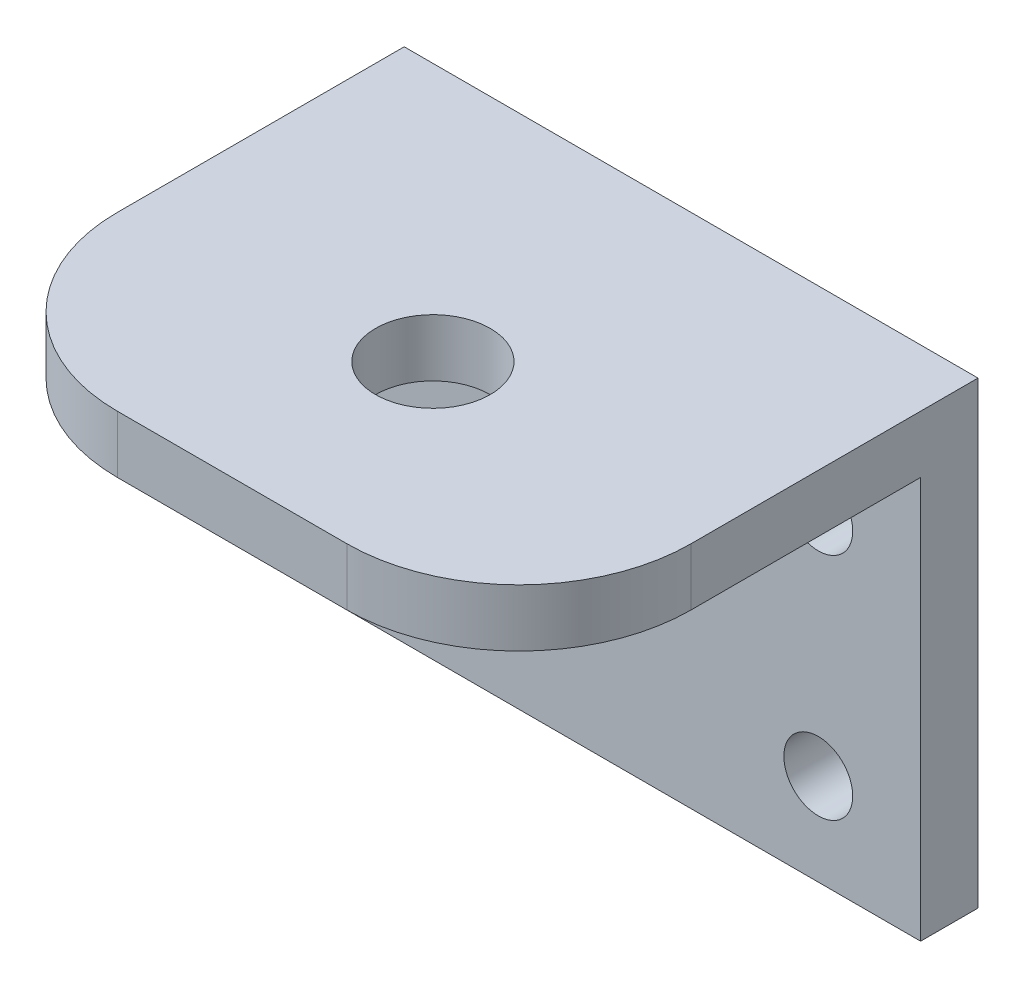
from build123d import *

# Parameters (mm, degrees)
SKETCH1_W           = 50
SKETCH1_H           = 40
BOSS_EXTRUDE1_DEPTH = 40
SKETCH5_W           = 50
SKETCH5_H           = 35
CUT_EXTRUDE1_DEPTH  = 35
SKETCH6_R           = 5
CUT_EXTRUDE2_DEPTH  = 6
SKETCH2_R           = 3
CUT_EXTRUDE3_DEPTH  = 10
FILLET1_R           = 15


with BuildPart() as part:
    # Sketch1 → Boss-Extrude1 (new body)
    with BuildSketch(Plane.XY):
        Rectangle(SKETCH1_W, SKETCH1_H)
    extrude(amount=BOSS_EXTRUDE1_DEPTH)

    # Sketch5 → Cut-Extrude1 (cut)
    with BuildSketch(Plane.XZ.offset(20)):
        with Locations((0, 22.5)):
            Rectangle(SKETCH5_W, SKETCH5_H)
    extrude(amount=-CUT_EXTRUDE1_DEPTH, mode=Mode.SUBTRACT)

    # Sketch6 → Cut-Extrude2 (cut, through all)
    with BuildSketch(Plane.XZ.offset(-15)):
        with Locations(Location((0, 22.5, 0), (0, 0, 270))):  # turned: the seam where the file's is
            Circle(SKETCH6_R)
    extrude(amount=-CUT_EXTRUDE2_DEPTH, mode=Mode.SUBTRACT)

    # Sketch2 → Cut-Extrude3 (cut)
    with BuildSketch(Plane(origin=(0, 0, 0), x_dir=(-1, 0, 0), z_dir=(0, 0, -1))):
        with Locations((13.917211686, -12)):
            Circle(SKETCH2_R)
        with Locations((-16.082788314, -12)):
            Circle(SKETCH2_R)
        with Locations((-16.082788314, 8)):
            Circle(SKETCH2_R)
        with Locations((13.917211686, 8)):
            Circle(SKETCH2_R)
    extrude(amount=-CUT_EXTRUDE3_DEPTH, mode=Mode.SUBTRACT)

    # Fillet1
    fillet1_edges = [part.edges().sort_by_distance(p)[0] for p in [
        (-25, 17.5, 40),
        (25, 17.5, 40),
    ]]
    fillet(fillet1_edges, radius=FILLET1_R)


solid = part.part
